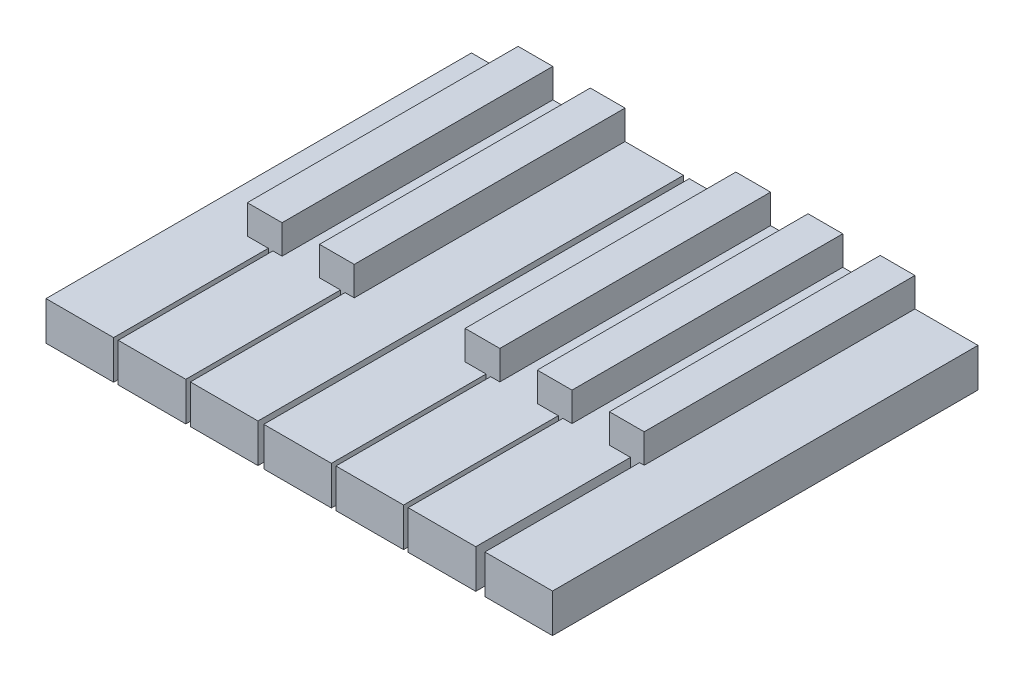
from build123d import *

# Parameters (mm, degrees)
BOSS_EXTRUDE1_DEPTH   = 12.7
BOSS_EXTRUDE1_2_DEPTH = 12.7
BOSS_EXTRUDE1_3_DEPTH = 12.7
BOSS_EXTRUDE1_4_DEPTH = 12.7
BOSS_EXTRUDE1_5_DEPTH = 12.7
BOSS_EXTRUDE1_6_DEPTH = 12.7
BOSS_EXTRUDE1_7_DEPTH = 12.7
SKETCH1_4_W           = 11.4
SKETCH1_4_H           = 88.9
BOSS_EXTRUDE2_DEPTH   = 22.225


with BuildPart() as part:
    # Sketch1 → Boss-Extrude1 (new body)
    with BuildSketch(Plane(origin=(0, 0, 0), x_dir=(1, 0, 0), z_dir=(0, 1, 0))):
        Polygon((15.3, -88.9), (15.3, 0), (0, 0), (0, -139.7), (22.2, -139.7), (22.2, -88.9), align=None)
    extrude(amount=BOSS_EXTRUDE1_DEPTH)



with BuildPart() as body_2:
    # Sketch1 → Boss-Extrude1 2 (new body)
    with BuildSketch(Plane(origin=(0, 0, 0), x_dir=(1, 0, 0), z_dir=(0, 1, 0))):
        Polygon((39, 0), (26.7, 0), (26.7, -88.9), (23.7, -88.9), (23.7, -139.7), (45.9, -139.7), (45.9, -88.9), (39, -88.9), align=None)
    extrude(amount=BOSS_EXTRUDE1_2_DEPTH)


with BuildPart() as body_3:
    # Sketch1 → Boss-Extrude1 3 (new body)
    with BuildSketch(Plane(origin=(0, 0, 0), x_dir=(1, 0, 0), z_dir=(0, 1, 0))):
        Polygon((69.6, 0), (50.4, 0), (50.4, -88.9), (47.4, -88.9), (47.4, -139.7), (69.6, -139.7), align=None)
    extrude(amount=BOSS_EXTRUDE1_3_DEPTH)


with BuildPart() as body_4:
    # Sketch1 → Boss-Extrude1 4 (new body)
    with BuildSketch(Plane(origin=(0, 0, 0), x_dir=(1, 0, 0), z_dir=(0, 1, 0))):
        Polygon((86.8, -88.9), (86.8, 0), (71.5, 0), (71.5, -139.7), (93.7, -139.7), (93.7, -88.9), align=None)
    extrude(amount=BOSS_EXTRUDE1_4_DEPTH)


with BuildPart() as body_5:
    # Sketch1 → Boss-Extrude1 5 (new body)
    with BuildSketch(Plane(origin=(0, 0, 0), x_dir=(1, 0, 0), z_dir=(0, 1, 0))):
        Polygon((110.5, 0), (98.2, 0), (98.2, -88.9), (95.2, -88.9), (95.2, -139.7), (117.4, -139.7), (117.4, -88.9), (110.5, -88.9), align=None)
    extrude(amount=BOSS_EXTRUDE1_5_DEPTH)


with BuildPart() as body_6:
    # Sketch1 → Boss-Extrude1 6 (new body)
    with BuildSketch(Plane(origin=(0, 0, 0), x_dir=(1, 0, 0), z_dir=(0, 1, 0))):
        Polygon((134.2, 0), (121.9, 0), (121.9, -88.9), (118.9, -88.9), (118.9, -139.7), (141.1, -139.7), (141.1, -88.9), (134.2, -88.9), align=None)
    extrude(amount=BOSS_EXTRUDE1_6_DEPTH)


with BuildPart() as body_7:
    # Sketch1 → Boss-Extrude1 7 (new body)
    with BuildSketch(Plane(origin=(0, 0, 0), x_dir=(1, 0, 0), z_dir=(0, 1, 0))):
        Polygon((166.3, 0), (145.6, 0), (145.6, -88.9), (144.1, -88.9), (144.1, -139.7), (166.3, -139.7), align=None)
    extrude(amount=BOSS_EXTRUDE1_7_DEPTH)


with BuildPart() as part_1:
    add(part.part)

    add(body_2.part)  # Boss-Extrude2 merges body 2

    add(body_3.part)  # Boss-Extrude2 merges body 3

    add(body_4.part)  # Boss-Extrude2 merges body 4

    add(body_5.part)  # Boss-Extrude2 merges body 5

    add(body_6.part)  # Boss-Extrude2 merges body 6
    # Sketch1_4 → Boss-Extrude2 (add)
    with BuildSketch(Plane(origin=(0, 0, 0), x_dir=(1, 0, 0), z_dir=(0, 1, 0))):
        with Locations((21, -44.45)):
            Rectangle(SKETCH1_4_W, SKETCH1_4_H)
        with Locations((44.7, -44.45)):
            Rectangle(SKETCH1_4_W, SKETCH1_4_H)
        with Locations((92.5, -44.45)):
            Rectangle(SKETCH1_4_W, SKETCH1_4_H)
        with Locations((116.2, -44.45)):
            Rectangle(SKETCH1_4_W, SKETCH1_4_H)
        with Locations((139.9, -44.45)):
            Rectangle(SKETCH1_4_W, SKETCH1_4_H)
    extrude(amount=BOSS_EXTRUDE2_DEPTH)


solid = Compound([body_7.part, part_1.part])
